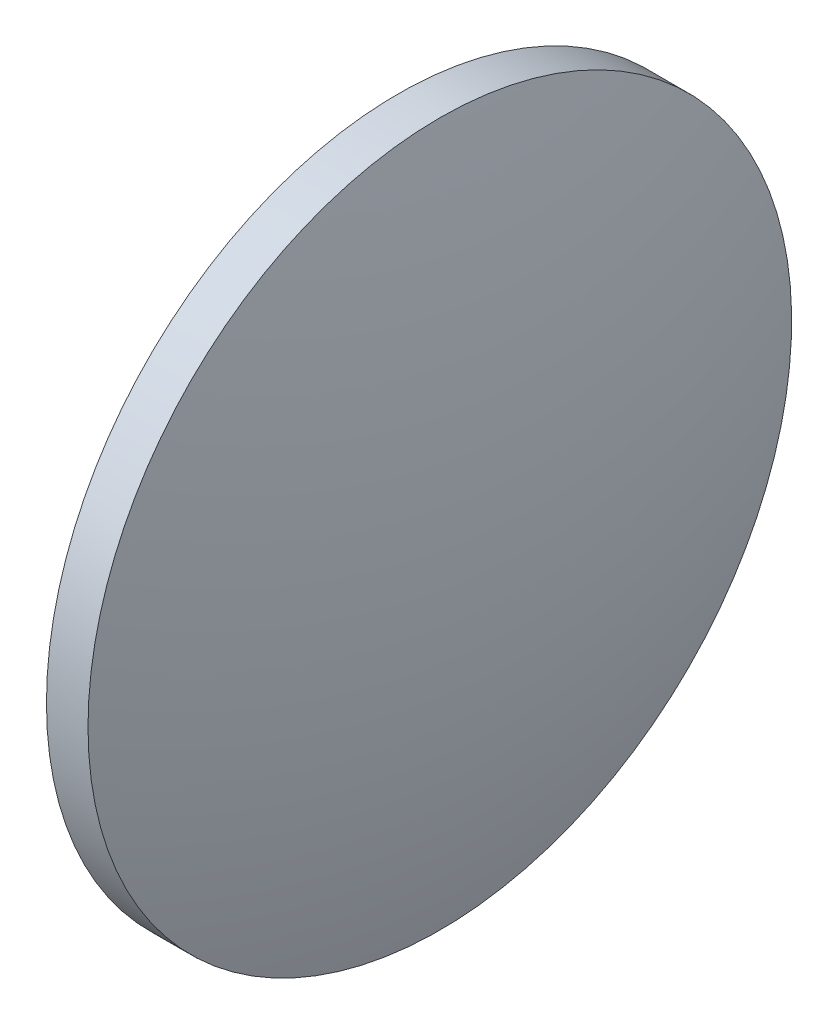
from build123d import *


with BuildPart() as part:
    # 草图2 → 旋转1 (revolve)
    with BuildSketch(Plane.XY):
        with BuildLine():
            Line((540.448599106, 103.517771117), (540.448599106, 128.917771117))
            Line((540.448599106, 128.917771117), (543.448599106, 128.917771117))
            ThreePointArc((543.448599106, 128.917771117), (546.144124132, 116.344695924), (547.048599106, 103.517771117))
            Line((547.048599106, 103.517771117), (540.448599106, 103.517771117))
        make_face()
    revolve(axis=Axis((528.758525484, 103.517771117, 0), (1, 0, 0)))


solid = part.part
